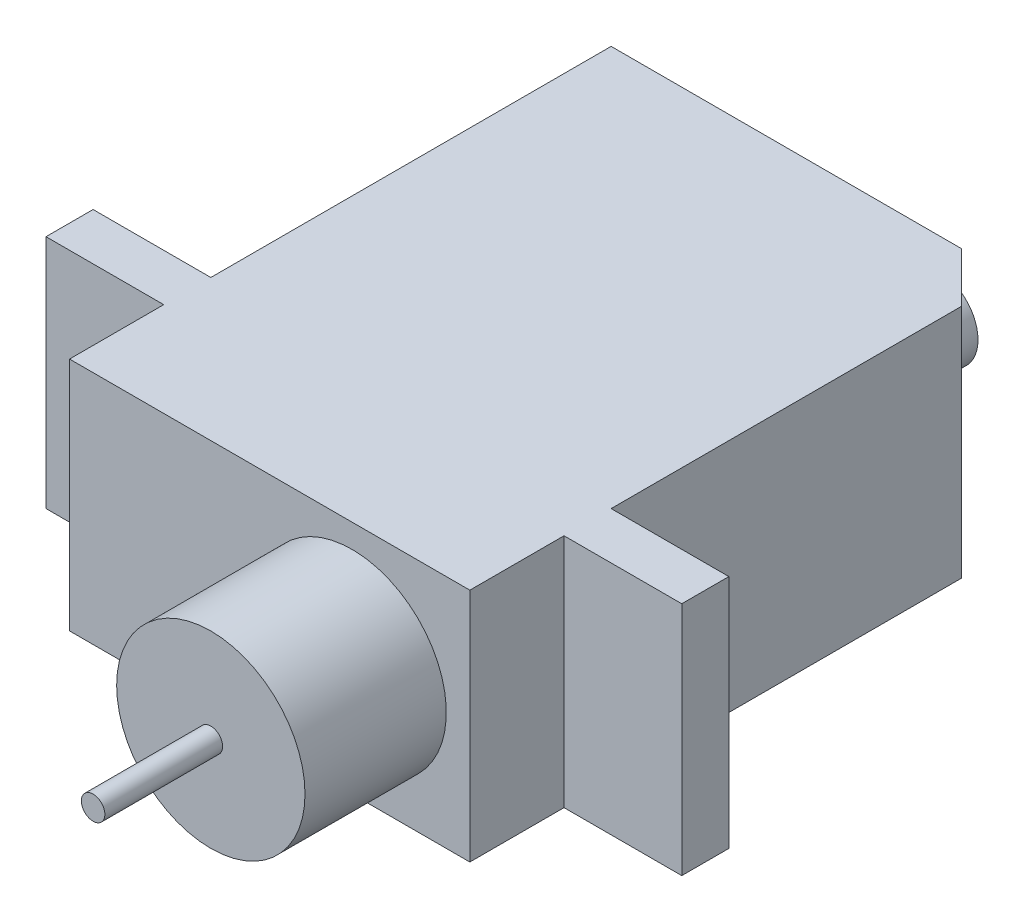
from build123d import *

# Parameters (mm, degrees)
BOSS_EXTRUDE1_DEPTH = 10
SKETCH2_R           = 4
BOSS_EXTRUDE2_DEPTH = 6
SKETCH3_R           = 0.5
BOSS_EXTRUDE3_DEPTH = 5
SKETCH4_R           = 1.701881869
BOSS_EXTRUDE4_DEPTH = 2


with BuildPart() as part:
    # Sketch1 → Boss-Extrude1 (new body)
    with BuildSketch(Plane(origin=(0, 0, 0), x_dir=(1, 0, 0), z_dir=(0, 1, 0))):
        Polygon((0, 0), (14.878679656, 0), (17, -2.121320344), (17, -17), (22, -17), (22, -19), (17, -19), (17, -23), (0, -23), (0, -19), (-5, -19), (-5, -17), (0, -17), align=None)
    extrude(amount=BOSS_EXTRUDE1_DEPTH)

    # Sketch2 → Boss-Extrude2 (add)
    with BuildSketch(Plane.XY.offset(23)):
        with Locations((12, 5)):
            Circle(SKETCH2_R)
    extrude(amount=BOSS_EXTRUDE2_DEPTH)

    # Sketch3 → Boss-Extrude3 (add)
    with BuildSketch(Plane.XY.offset(29)):
        with Locations((12, 5)):
            Circle(SKETCH3_R)
    extrude(amount=BOSS_EXTRUDE3_DEPTH)

    # Sketch4 → Boss-Extrude4 (add)
    with BuildSketch(Plane(origin=(0, 0, 0), x_dir=(-1, 0, 0), z_dir=(0, 0, -1))):
        with Locations((-11.878679656, 5)):
            Circle(SKETCH4_R)
    extrude(amount=BOSS_EXTRUDE4_DEPTH)


solid = part.part
